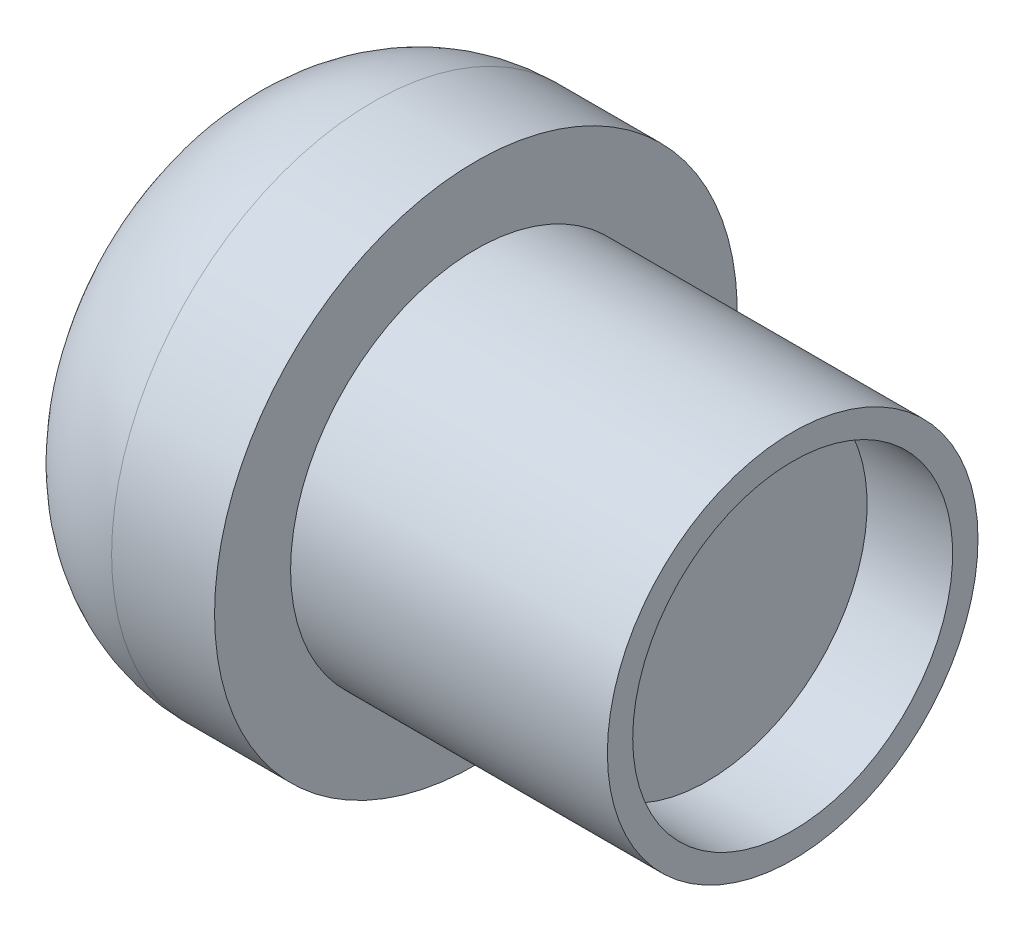
from build123d import *


with BuildPart() as part:
    # Skizze1 → Rotation1 (revolve)
    with BuildSketch(Plane.XY):
        with BuildLine():
            Line((0, 0), (-10, 0))
            Line((-10, 0), (-10, 2.4))
            Line((-10, 2.4), (-13.25, 2.4))
            ThreePointArc((-13.25, 2.4), (-16.785533906, 0.935533906), (-18.25, -2.6))
            Line((-18.25, -2.6), (-18.25, -5.85))
            Line((-18.25, -5.85), (-2.7, -5.85))
            Line((-2.7, -5.85), (-2.7, -0.8))
            Line((-2.7, -0.8), (0, -0.8))
            Line((0, -0.8), (0, 0))
        make_face()
    revolve(axis=Axis((-27.302993085, -5.85, 0), (1, 0, 0)))


solid = part.part
